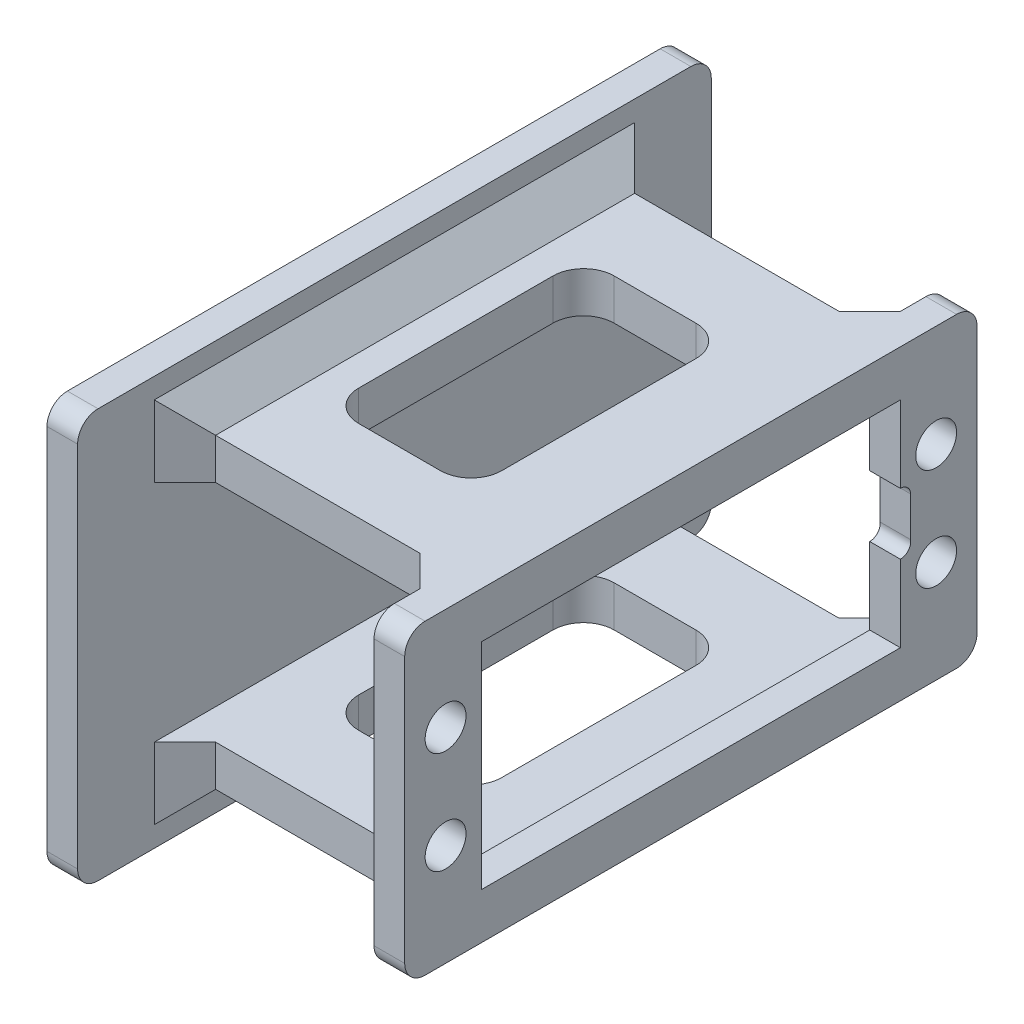
from build123d import *

# Parameters (mm, degrees)
SKETCH_1_W          = 56
SKETCH_1_H          = 30
SKETCH_1_R          = 2
EXTRUDE_1_DEPTH     = 3
SKETCH_2_W          = 41
SKETCH_2_H          = 4
EXTRUDE_2_DEPTH     = 26
SKETCH_3_W          = 62
SKETCH_3_H          = 40
EXTRUDE_3_DEPTH     = 3
CHAMFER_2_SIZE      = 3
CUT_EXTRUDE_1_DEPTH = 36
FILLET_1_R          = 2
CHAMFER_3_SIZE      = 3
CHAMFER_4_SIZE      = 3


with BuildPart() as part:
    # Эскиз1 → Бобышка-Вытянуть1 (new body)
    with BuildSketch(Plane(origin=(0, 0, 0), x_dir=(0, 0, -1), z_dir=(1, 0, 0))):
        with Locations((-20.5, 10.5)):
            Rectangle(SKETCH_1_W, SKETCH_1_H)
        with Locations((3.5, 15.5)):
            Circle(SKETCH_1_R, mode=Mode.SUBTRACT)
        with Locations((3.5, 5.5)):
            Circle(SKETCH_1_R, mode=Mode.SUBTRACT)
        with Locations((-44.5, 5.5)):
            Circle(SKETCH_1_R, mode=Mode.SUBTRACT)
        with Locations((-44.5, 15.5)):
            Circle(SKETCH_1_R, mode=Mode.SUBTRACT)
        with BuildLine():
            Line((0, 0), (-41, 0))
            Line((-41, 0), (-41, 21))
            Line((-41, 21), (0, 21))
            Line((0, 21), (0, 13.499943953))
            ThreePointArc((0, 13.499943953), (0.695596702, 13.218912412), (1, 12.533221423))
            Line((1, 12.533221423), (1, 8.663676138))
            ThreePointArc((1, 8.663676138), (0.771906654, 7.848193044), (0, 7.500056047))
            Line((0, 7.500056047), (0, 0))
        make_face(mode=Mode.SUBTRACT)
    extrude(amount=EXTRUDE_1_DEPTH)

    # Эскиз2 → Бобышка-Вытянуть2 (add)
    with BuildSketch(Plane.ZY):
        with Locations((20.5, 23.5)):
            Rectangle(SKETCH_2_W, SKETCH_2_H)
        with Locations((20.5, -2.5)):
            Rectangle(SKETCH_2_W, SKETCH_2_H)
    extrude(amount=EXTRUDE_2_DEPTH)

    # Эскиз3 → Бобышка-Вытянуть3 (add)
    with BuildSketch(Plane.ZY.offset(26)):
        with Locations((20.5, 10.5)):
            Rectangle(SKETCH_3_W, SKETCH_3_H)
    extrude(amount=EXTRUDE_3_DEPTH)

    # Фаска2
    chamfer_2_edges = [part.edges().sort_by_distance(p)[0] for p in [
        (-26, 25.5, 20.5),
        (-26, -4.5, 20.5),
    ]]
    chamfer(chamfer_2_edges, length=CHAMFER_2_SIZE)

    # Эскиз4 → Вырез-Вытянуть1 (cut, through all)
    with BuildSketch(Plane.XZ.offset(4.5)):
        with BuildLine():
            Line((-17, 33), (-9, 33))
            ThreePointArc((-9, 33), (-6.878679656, 32.121320344), (-6, 30))
            Line((-6, 30), (-6, 11))
            ThreePointArc((-6, 11), (-6.878679656, 8.878679656), (-9, 8))
            Line((-9, 8), (-17, 8))
            ThreePointArc((-17, 8), (-19.121320344, 8.878679656), (-20, 11))
            Line((-20, 11), (-20, 30))
            ThreePointArc((-20, 30), (-19.121320344, 32.121320344), (-17, 33))
        make_face()
    extrude(amount=-CUT_EXTRUDE_1_DEPTH, mode=Mode.SUBTRACT)

    # Скругление1
    fillet_1_edges = [part.edges().sort_by_distance(p)[0] for p in [
        (1.5, -4.5, -7.5),
        (1.5, -4.5, 48.5),
        (1.5, 25.5, 48.5),
        (1.5, 25.5, -7.5),
        (-27.5, 30.5, -10.5),
        (-27.5, -9.5, -10.5),
        (-27.5, -9.5, 51.5),
        (-27.5, 30.5, 51.5),
    ]]
    fillet(fillet_1_edges, radius=FILLET_1_R)

    # Фаска3
    chamfer_3_edges = [part.edges().sort_by_distance(p)[0] for p in [
        (0, 23.5, 0),
        (0, 23.5, 41),
        (0, -2.5, 0),
        (0, -2.5, 41),
    ]]
    chamfer(chamfer_3_edges, length=CHAMFER_3_SIZE)

    # Фаска4
    chamfer_4_edges = [part.edges().sort_by_distance(p)[0] for p in [
        (-26, 25, 0),
        (-26, -4, 0),
        (-26, 25, 41),
        (-26, -4, 41),
    ]]
    chamfer(chamfer_4_edges, length=CHAMFER_4_SIZE)


solid = part.part
